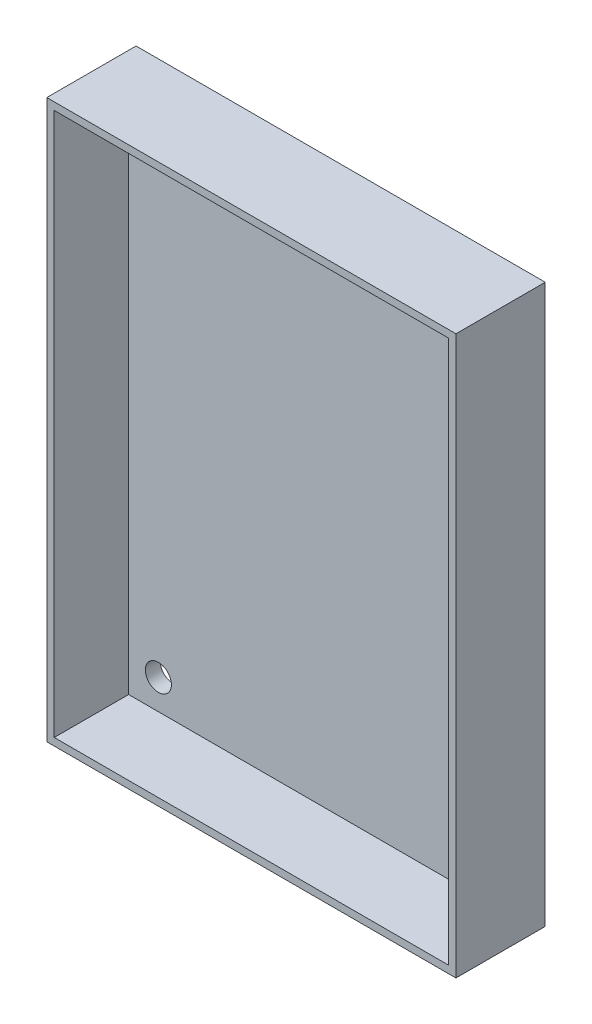
from build123d import *

# Parameters (mm, degrees)
SKETCH_1_W      = 55
SKETCH_1_H      = 75
SKETCH_1_R      = 1.75
EXTRUDE_1_DEPTH = 2
SKETCH_2_W      = 55
SKETCH_2_H      = 75
SKETCH_2_W_2    = 53
SKETCH_2_H_2    = 73
EXTRUDE_2_DEPTH = 10


with BuildPart() as part:
    # Эскиз1 → Бобышка-Вытянуть1 (new body)
    with BuildSketch(Plane.XY):
        with Locations((27.5, 37.5)):
            Rectangle(SKETCH_1_W, SKETCH_1_H)
        with Locations((5, 70)):
            Circle(SKETCH_1_R, mode=Mode.SUBTRACT)
        with Locations((50, 70)):
            Circle(SKETCH_1_R, mode=Mode.SUBTRACT)
        with Locations((5, 5)):
            Circle(SKETCH_1_R, mode=Mode.SUBTRACT)
        with Locations((50, 5)):
            Circle(SKETCH_1_R, mode=Mode.SUBTRACT)
    extrude(amount=EXTRUDE_1_DEPTH)

    # Эскиз2 → Бобышка-Вытянуть2 (add)
    with BuildSketch(Plane.XY.offset(2)):
        with Locations((27.5, 37.5)):
            Rectangle(SKETCH_2_W, SKETCH_2_H)
        with Locations((27.5, 37.5)):
            Rectangle(SKETCH_2_W_2, SKETCH_2_H_2, mode=Mode.SUBTRACT)
    extrude(amount=EXTRUDE_2_DEPTH)


solid = part.part
